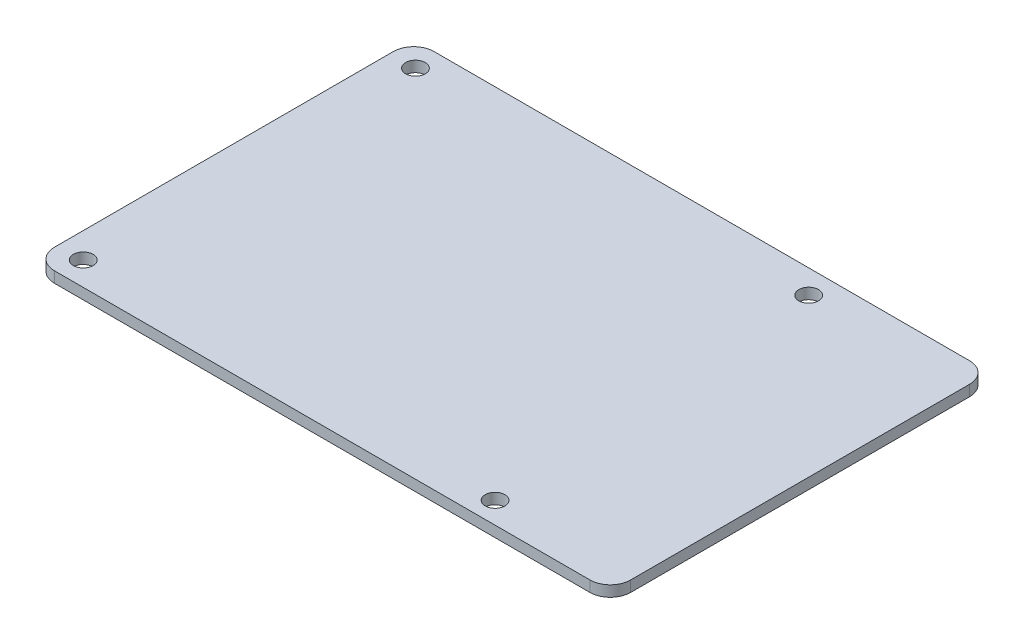
from build123d import *

# Parameters (mm, degrees)
BOSS_EXTRUDE1_DEPTH    = 1.6
M2_5_CLEARANCE_HOLE1_D = 2.9


with BuildPart() as part:
    # Sketch1 → Boss-Extrude1 (new body)
    with BuildSketch(Plane(origin=(0, 0, 0), x_dir=(1, 0, 0), z_dir=(0, 1, 0))):
        with BuildLine():
            Line((-39.5, 28), (39.5, 28))
            ThreePointArc((39.5, 28), (41.621320344, 27.121320344), (42.5, 25))
            Line((42.5, 25), (42.5, -25))
            ThreePointArc((42.5, -25), (41.621320344, -27.121320344), (39.5, -28))
            Line((39.5, -28), (-39.5, -28))
            ThreePointArc((-39.5, -28), (-41.621320344, -27.121320344), (-42.5, -25))
            Line((-42.5, -25), (-42.5, 25))
            ThreePointArc((-42.5, 25), (-41.621320344, 27.121320344), (-39.5, 28))
        make_face()
    extrude(amount=BOSS_EXTRUDE1_DEPTH)

    # M2.5 Clearance Hole1 (through all)
    with Locations(Plane(origin=(0, 1.6, 0), x_dir=(1, 0, 0), z_dir=(0, 1, 0))):
        with Locations((-38.742784227, 24.5), (19.257215773, 24.5), (22.326862543, -24.824918993), (-38.742784227, -24.5)):
            Hole(M2_5_CLEARANCE_HOLE1_D / 2)


solid = part.part
